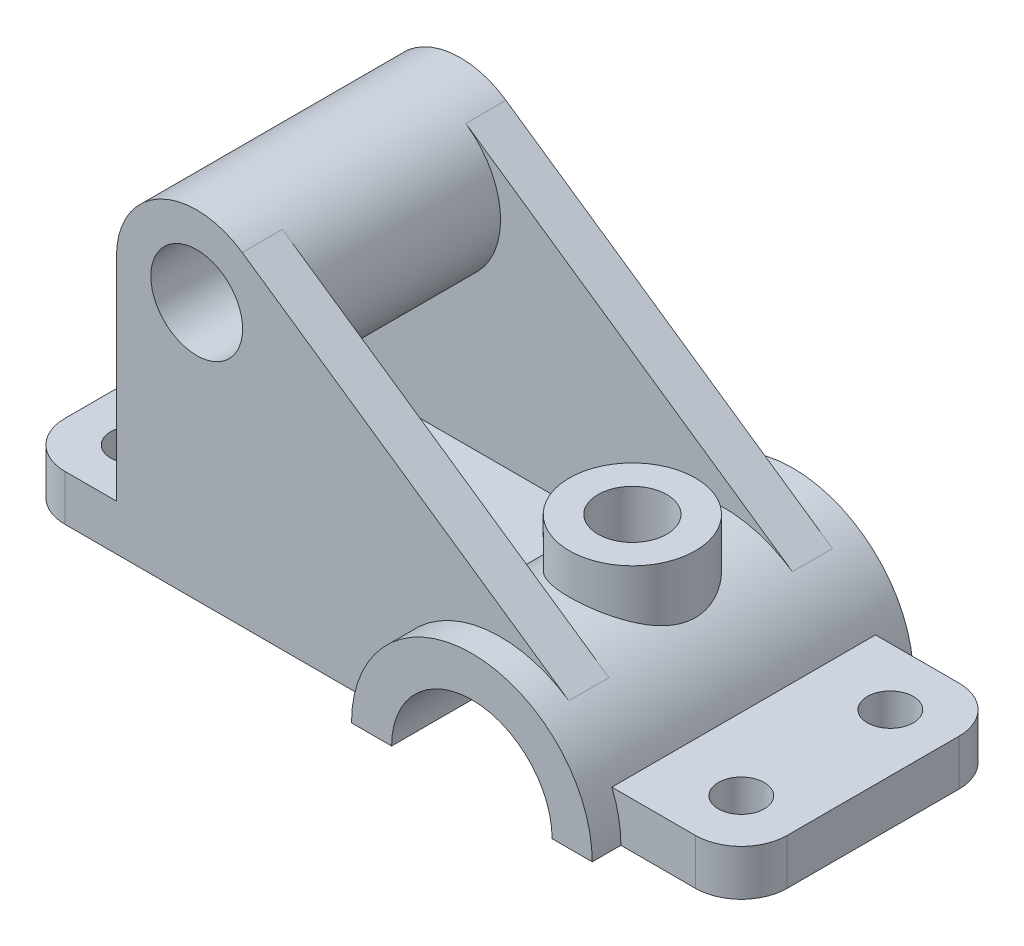
from build123d import *

# Parameters (mm, degrees)
SKETCH1_R                = 4
BOSS_EXTRUDE1_DEPTH      = 8
BOSS_EXTRUDE2_DEPTH      = 5
BOSS_EXTRUDE2_DEPTH_BACK = 51
BOSS_EXTRUDE3_DEPTH      = 7
BOSS_EXTRUDE5_REACH      = 46
SKETCH7_R                = 14
SKETCH4_R                = 11
BOSS_EXTRUDE4_DEPTH      = 28
CUT_EXTRUDE1_REACH       = 58
SKETCH5_R                = 14
SKETCH5_R_2              = 8
SKETCH6_R                = 6
CUT_EXTRUDE2_DEPTH       = 28


with BuildPart() as part:
    # Sketch1 → Boss-Extrude1 (new body)
    with BuildSketch(Plane(origin=(0, 0, 0), x_dir=(1, 0, 0), z_dir=(0, 1, 0))):
        with BuildLine():
            Line((55, -23), (-55, -23))
            ThreePointArc((-55, -23), (-60.656854249, -20.656854249), (-63, -15))
            Line((-63, -15), (-63, 15))
            ThreePointArc((-63, 15), (-60.656854249, 20.656854249), (-55, 23))
            Line((-55, 23), (55, 23))
            ThreePointArc((55, 23), (60.656854249, 20.656854249), (63, 15))
            Line((63, 15), (63, -15))
            ThreePointArc((63, -15), (60.656854249, -20.656854249), (55, -23))
        make_face()
        with Locations(Location((-53, 13, 0), (0, 0, 270))):  # turned: the seam where the file's is
            Circle(SKETCH1_R, mode=Mode.SUBTRACT)
        with Locations(Location((53, 13, 0), (0, 0, 270))):  # turned: the seam where the file's is
            Circle(SKETCH1_R, mode=Mode.SUBTRACT)
        with Locations(Location((-53, -13, 0), (0, 0, 270))):  # turned: the seam where the file's is
            Circle(SKETCH1_R, mode=Mode.SUBTRACT)
        with Locations(Location((53, -13, 0), (0, 0, 270))):  # turned: the seam where the file's is
            Circle(SKETCH1_R, mode=Mode.SUBTRACT)
    extrude(amount=BOSS_EXTRUDE1_DEPTH)

    # Sketch2 → Boss-Extrude2 (add, two sides)
    with BuildSketch(Plane.XY.offset(23)) as boss_extrude2_sk:
        with BuildLine():
            Line((0, 0), (42, 0))
            ThreePointArc((42, 0), (21, 21), (0, 0))
        make_face()
    extrude(amount=BOSS_EXTRUDE2_DEPTH)
    extrude(boss_extrude2_sk.sketch, amount=-BOSS_EXTRUDE2_DEPTH_BACK)

    # Sketch3 → Boss-Extrude3 (add)
    with BuildSketch(Plane.XY.offset(23)):
        with BuildLine():
            Line((-46, 45), (-46, 0))
            Line((-46, 0), (0, 0))
            ThreePointArc((0, 0), (11.23098253, 18.589413591), (32.911075968, 17.295267251))
            Line((32.911075968, 17.295267251), (-24.059282688, 56.530178167))
            ThreePointArc((-24.059282688, 56.530178167), (-38.512678314, 57.392942394), (-46, 45))
        make_face()
    boss_extrude3 = extrude(amount=-BOSS_EXTRUDE3_DEPTH)

    # Mirror1: Boss-Extrude3 across plane
    add(boss_extrude3.mirror(Plane.XY))

    # Sketch7 → Boss-Extrude5 (add, up to next)
    with BuildSketch(Plane(origin=(0, 0, 16), x_dir=(-1, 0, 0), z_dir=(0, 0, -1)), mode=Mode.PRIVATE) as boss_extrude5_sk1:
        with Locations(Location((32, 45, 0), (0, 0, 124.554792234))):  # turned: the seam where the file's is
            Circle(SKETCH7_R)
    boss_extrude5_tool1 = extrude(boss_extrude5_sk1.sketch, amount=BOSS_EXTRUDE5_REACH, mode=Mode.PRIVATE) - part.part
    add(boss_extrude5_tool1.solids().sort_by_distance((-32, 45, 16))[0])

    # Sketch4 → Boss-Extrude4 (add)
    with BuildSketch(Plane.XZ):
        with Locations(Location((21, 0, 0), (0, 0, 270))):  # turned: the seam where the file's is
            Circle(SKETCH4_R)
    extrude(amount=-BOSS_EXTRUDE4_DEPTH)

    # Sketch5 → Cut-Extrude1 (cut, up to next)
    with BuildSketch(Plane.XY.offset(28), mode=Mode.PRIVATE) as cut_extrude1_sk1:
        with Locations((21, 0)):
            Circle(SKETCH5_R)
    cut_extrude1_tool1 = extrude(cut_extrude1_sk1.sketch, amount=-CUT_EXTRUDE1_REACH, mode=Mode.PRIVATE) & part.part
    add(cut_extrude1_tool1.solids().sort_by_distance((21, 0, 28))[0], mode=Mode.SUBTRACT)
    # Sketch5 → Cut-Extrude1 (cut, up to next)
    with BuildSketch(Plane.XY.offset(28), mode=Mode.PRIVATE) as cut_extrude1_sk2:
        with Locations((-32, 45)):
            Circle(SKETCH5_R_2)
    cut_extrude1_tool2 = extrude(cut_extrude1_sk2.sketch, amount=-CUT_EXTRUDE1_REACH, mode=Mode.PRIVATE) & part.part
    add(cut_extrude1_tool2.solids().sort_by_distance((-32, 45, 28))[0], mode=Mode.SUBTRACT)

    # Sketch6 → Cut-Extrude2 (cut)
    with BuildSketch(Plane(origin=(0, 28, 0), x_dir=(1, 0, 0), z_dir=(0, 1, 0))):
        with Locations(Location((21, 0, 0), (0, 0, 270))):  # turned: the seam where the file's is
            Circle(SKETCH6_R)
    extrude(amount=-CUT_EXTRUDE2_DEPTH, mode=Mode.SUBTRACT)


solid = part.part
